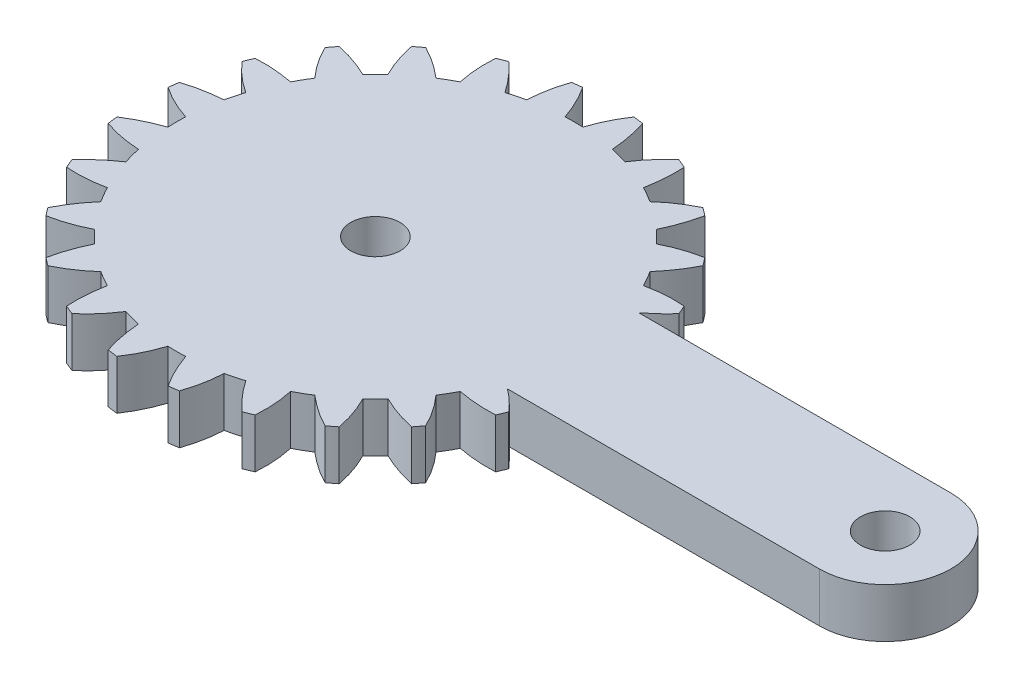
from build123d import *

# Parameters (mm, degrees)
SKETCH2_R           = 1.5
BOSS_EXTRUDE1_DEPTH = 3
SCALE1_SCALE        = 1.8


with BuildPart() as part:
    # Sketch2 → Boss-Extrude1 (new body)
    with BuildSketch(Plane(origin=(0, 0, 0), x_dir=(1, 0, 0), z_dir=(0, 1, 0))):
        with BuildLine():
            Line((31, 4.000000001), (12.012859152, 4.000000001))
            add(Edge.make_bspline(
                [(13.278985865, 5.170206419), (12.8954662, 4.733530556), (12.462190225, 4.344528056), (12.012859152, 4.000000001)],
                knots=[0.154712813, 0.154712813, 0.154712813, 0.154712813, 0.777489596, 0.777489596, 0.777489596, 0.777489596], degree=3))
            ThreePointArc((13.278985865, 5.170206419), (13.165283338, 5.453238911), (13.045548971, 5.733772933))
            add(Edge.make_bspline(
                [(10.729735914, 5.571433139), (11.468148216, 5.731782959), (12.25282672, 5.797378255), (13.045548971, 5.733772933)],
                knots=[0, 0, 0, 0, 0.84522739, 0.84522739, 0.84522739, 0.84522739], degree=3))
            ThreePointArc((10.729735914, 5.571433139), (10.602635836, 5.809665509), (10.470247132, 6.045))
            ThreePointArc((10.470247132, 6.045), (10.332600838, 6.277376835), (10.189798038, 6.506620931))
            add(Edge.make_bspline(
                [(11.488367505, 8.430890348), (11.138958904, 7.723663869), (10.678280228, 7.077546079), (10.189798038, 6.506620931)],
                knots=[0.154712813, 0.154712813, 0.154712813, 0.154712813, 1, 1, 1, 1], degree=3))
            ThreePointArc((11.488367505, 8.430890348), (11.305285099, 8.674850363), (11.117023034, 8.914835886))
            add(Edge.make_bspline(
                [(8.922136024, 8.158651162), (9.593885949, 8.504652361), (10.334849869, 8.771102293), (11.117023034, 8.914835886)],
                knots=[0, 0, 0, 0, 0.84522739, 0.84522739, 0.84522739, 0.84522739], degree=3))
            ThreePointArc((8.922136024, 8.158651162), (8.737707702, 8.35587004), (8.548920985, 8.548920985))
            ThreePointArc((8.548920985, 8.548920985), (8.355821324, 8.737754288), (8.158551674, 8.922226997))
            add(Edge.make_bspline(
                [(8.914835886, 11.117023034), (8.760376776, 10.343461111), (8.482622935, 9.600126837), (8.158551674, 8.922226997)],
                knots=[0.154712813, 0.154712813, 0.154712813, 0.154712813, 1, 1, 1, 1], degree=3))
            ThreePointArc((8.914835886, 11.117023034), (8.674850363, 11.305285099), (8.430890348, 11.488367505))
            add(Edge.make_bspline(
                [(6.506507308, 10.189870591), (7.065816209, 10.697943759), (7.71257008, 11.147090204), (8.430890348, 11.488367505)],
                knots=[0, 0, 0, 0, 0.84522739, 0.84522739, 0.84522739, 0.84522739], degree=3))
            ThreePointArc((6.506507308, 10.189870591), (6.277319227, 10.332635836), (6.045, 10.470247132))
            ThreePointArc((6.045, 10.470247132), (5.809606396, 10.602668227), (5.571313495, 10.729798038))
            add(Edge.make_bspline(
                [(5.733772933, 13.045548971), (5.784789448, 12.258368573), (5.708888907, 11.468474815), (5.571313495, 10.729798038)],
                knots=[0.154712813, 0.154712813, 0.154712813, 0.154712813, 1, 1, 1, 1], degree=3))
            ThreePointArc((5.733772933, 13.045548971), (5.453238911, 13.165283338), (5.170206419, 13.278985865))
            add(Edge.make_bspline(
                [(3.647470872, 11.526667178), (4.056222772, 12.16218797), (4.564691385, 12.76342234), (5.170206419, 13.278985865)],
                knots=[0, 0, 0, 0, 0.84522739, 0.84522739, 0.84522739, 0.84522739], degree=3))
            ThreePointArc((3.647470872, 11.526667178), (3.389141821, 11.605249576), (3.129122255, 11.67804324))
            ThreePointArc((3.129122255, 11.67804324), (2.867476392, 11.745027848), (2.604399509, 11.806151075))
            add(Edge.make_bspline(
                [(2.161962831, 14.085042304), (2.414978279, 13.337888473), (2.546103534, 12.555265188), (2.604399509, 11.806151075)],
                knots=[0.154712813, 0.154712813, 0.154712813, 0.154712813, 1, 1, 1, 1], degree=3))
            ThreePointArc((2.161962831, 14.085042304), (1.859998239, 14.128089275), (1.557181466, 14.164663282))
            add(Edge.make_bspline(
                [(0.539865323, 12.077940447), (0.770204456, 12.797599169), (1.105736515, 13.509948335), (1.557181466, 14.164663282)],
                knots=[0, 0, 0, 0, 0.84522739, 0.84522739, 0.84522739, 0.84522739], degree=3))
            ThreePointArc((0.539865323, 12.077940447), (0.27, 12.086984736), (0, 12.09))
            ThreePointArc((0, 12.09), (-0.270067389, 12.08698323), (-0.54, 12.077934426))
            add(Edge.make_bspline(
                [(-1.557181466, 14.164663282), (-1.119409669, 13.508453317), (-0.790194587, 12.786434986), (-0.54, 12.077934426)],
                knots=[0.154712813, 0.154712813, 0.154712813, 0.154712813, 1, 1, 1, 1], degree=3))
            ThreePointArc((-1.557181466, 14.164663282), (-1.859998239, 14.128089275), (-2.161962831, 14.085042304))
            add(Edge.make_bspline(
                [(-2.604531155, 11.806122033), (-2.568302021, 12.560875133), (-2.42857247, 13.335793678), (-2.161962831, 14.085042304)],
                knots=[0, 0, 0, 0, 0.84522739, 0.84522739, 0.84522739, 0.84522739], degree=3))
            ThreePointArc((-2.604531155, 11.806122033), (-2.867541874, 11.74501186), (-3.129122255, 11.67804324))
            ThreePointArc((-3.129122255, 11.67804324), (-3.389206524, 11.60523068), (-3.647599401, 11.526626506))
            add(Edge.make_bspline(
                [(-5.170206419, 13.278985865), (-4.577511698, 12.75843939), (-4.072642252, 12.146230371), (-3.647599401, 11.526626506)],
                knots=[0.154712813, 0.154712813, 0.154712813, 0.154712813, 1, 1, 1, 1], degree=3))
            ThreePointArc((-5.170206419, 13.278985865), (-5.453238911, 13.165283338), (-5.733772933, 13.045548971))
            add(Edge.make_bspline(
                [(-5.571433139, 10.729735914), (-5.731782959, 11.468148216), (-5.797378255, 12.25282672), (-5.733772933, 13.045548971)],
                knots=[0, 0, 0, 0, 0.84522739, 0.84522739, 0.84522739, 0.84522739], degree=3))
            ThreePointArc((-5.571433139, 10.729735914), (-5.809665509, 10.602635836), (-6.045, 10.470247132))
            ThreePointArc((-6.045, 10.470247132), (-6.277376835, 10.332600838), (-6.506620931, 10.189798038))
            add(Edge.make_bspline(
                [(-8.430890348, 11.488367505), (-7.723663869, 11.138958904), (-7.077546079, 10.678280228), (-6.506620931, 10.189798038)],
                knots=[0.154712813, 0.154712813, 0.154712813, 0.154712813, 1, 1, 1, 1], degree=3))
            ThreePointArc((-8.430890348, 11.488367505), (-8.674850363, 11.305285099), (-8.914835886, 11.117023034))
            add(Edge.make_bspline(
                [(-8.158651162, 8.922136024), (-8.504652361, 9.593885949), (-8.771102293, 10.334849869), (-8.914835886, 11.117023034)],
                knots=[0, 0, 0, 0, 0.84522739, 0.84522739, 0.84522739, 0.84522739], degree=3))
            ThreePointArc((-8.158651162, 8.922136024), (-8.35587004, 8.737707702), (-8.548920985, 8.548920985))
            ThreePointArc((-8.548920985, 8.548920985), (-8.737754288, 8.355821324), (-8.922226997, 8.158551674))
            add(Edge.make_bspline(
                [(-11.117023034, 8.914835886), (-10.343461111, 8.760376776), (-9.600126837, 8.482622935), (-8.922226997, 8.158551674)],
                knots=[0.154712813, 0.154712813, 0.154712813, 0.154712813, 1, 1, 1, 1], degree=3))
            ThreePointArc((-11.117023034, 8.914835886), (-11.305285099, 8.674850363), (-11.488367505, 8.430890348))
            add(Edge.make_bspline(
                [(-10.189870591, 6.506507308), (-10.697943759, 7.065816209), (-11.147090204, 7.71257008), (-11.488367505, 8.430890348)],
                knots=[0, 0, 0, 0, 0.84522739, 0.84522739, 0.84522739, 0.84522739], degree=3))
            ThreePointArc((-10.189870591, 6.506507308), (-10.332635836, 6.277319227), (-10.470247132, 6.045))
            ThreePointArc((-10.470247132, 6.045), (-10.602668227, 5.809606396), (-10.729798038, 5.571313495))
            add(Edge.make_bspline(
                [(-13.045548971, 5.733772933), (-12.258368573, 5.784789448), (-11.468474815, 5.708888907), (-10.729798038, 5.571313495)],
                knots=[0.154712813, 0.154712813, 0.154712813, 0.154712813, 1, 1, 1, 1], degree=3))
            ThreePointArc((-13.045548971, 5.733772933), (-13.165283338, 5.453238911), (-13.278985865, 5.170206419))
            add(Edge.make_bspline(
                [(-11.526667178, 3.647470872), (-12.16218797, 4.056222772), (-12.76342234, 4.564691385), (-13.278985865, 5.170206419)],
                knots=[0, 0, 0, 0, 0.84522739, 0.84522739, 0.84522739, 0.84522739], degree=3))
            ThreePointArc((-11.526667178, 3.647470872), (-11.605249576, 3.389141821), (-11.67804324, 3.129122255))
            ThreePointArc((-11.67804324, 3.129122255), (-11.745027848, 2.867476392), (-11.806151075, 2.604399509))
            add(Edge.make_bspline(
                [(-14.085042304, 2.161962831), (-13.337888473, 2.414978279), (-12.555265188, 2.546103534), (-11.806151075, 2.604399509)],
                knots=[0.154712813, 0.154712813, 0.154712813, 0.154712813, 1, 1, 1, 1], degree=3))
            ThreePointArc((-14.085042304, 2.161962831), (-14.128089275, 1.859998239), (-14.164663282, 1.557181466))
            add(Edge.make_bspline(
                [(-12.077940447, 0.539865323), (-12.797599169, 0.770204456), (-13.509948335, 1.105736515), (-14.164663282, 1.557181466)],
                knots=[0, 0, 0, 0, 0.84522739, 0.84522739, 0.84522739, 0.84522739], degree=3))
            ThreePointArc((-12.077940447, 0.539865323), (-12.086984736, 0.27), (-12.09, 0))
            ThreePointArc((-12.09, 0), (-12.08698323, -0.270067389), (-12.077934426, -0.54))
            add(Edge.make_bspline(
                [(-14.164663282, -1.557181466), (-13.508453317, -1.119409669), (-12.786434986, -0.790194587), (-12.077934426, -0.54)],
                knots=[0.154712813, 0.154712813, 0.154712813, 0.154712813, 1, 1, 1, 1], degree=3))
            ThreePointArc((-14.164663282, -1.557181466), (-14.128089275, -1.859998239), (-14.085042304, -2.161962831))
            add(Edge.make_bspline(
                [(-11.806122033, -2.604531155), (-12.560875133, -2.568302021), (-13.335793678, -2.42857247), (-14.085042304, -2.161962831)],
                knots=[0, 0, 0, 0, 0.84522739, 0.84522739, 0.84522739, 0.84522739], degree=3))
            ThreePointArc((-11.806122033, -2.604531155), (-11.74501186, -2.867541874), (-11.67804324, -3.129122255))
            ThreePointArc((-11.67804324, -3.129122255), (-11.60523068, -3.389206524), (-11.526626506, -3.647599401))
            add(Edge.make_bspline(
                [(-13.278985865, -5.170206419), (-12.75843939, -4.577511698), (-12.146230371, -4.072642252), (-11.526626506, -3.647599401)],
                knots=[0.154712813, 0.154712813, 0.154712813, 0.154712813, 1, 1, 1, 1], degree=3))
            ThreePointArc((-13.278985865, -5.170206419), (-13.165283338, -5.453238911), (-13.045548971, -5.733772933))
            add(Edge.make_bspline(
                [(-10.729735914, -5.571433139), (-11.468148216, -5.731782959), (-12.25282672, -5.797378255), (-13.045548971, -5.733772933)],
                knots=[0, 0, 0, 0, 0.84522739, 0.84522739, 0.84522739, 0.84522739], degree=3))
            ThreePointArc((-10.729735914, -5.571433139), (-10.602635836, -5.809665509), (-10.470247132, -6.045))
            ThreePointArc((-10.470247132, -6.045), (-10.332600838, -6.277376835), (-10.189798038, -6.506620931))
            add(Edge.make_bspline(
                [(-11.488367505, -8.430890348), (-11.138958904, -7.723663869), (-10.678280228, -7.077546079), (-10.189798038, -6.506620931)],
                knots=[0.154712813, 0.154712813, 0.154712813, 0.154712813, 1, 1, 1, 1], degree=3))
            ThreePointArc((-11.488367505, -8.430890348), (-11.305285099, -8.674850363), (-11.117023034, -8.914835886))
            add(Edge.make_bspline(
                [(-8.922136024, -8.158651162), (-9.593885949, -8.504652361), (-10.334849869, -8.771102293), (-11.117023034, -8.914835886)],
                knots=[0, 0, 0, 0, 0.84522739, 0.84522739, 0.84522739, 0.84522739], degree=3))
            ThreePointArc((-8.922136024, -8.158651162), (-8.737707702, -8.35587004), (-8.548920985, -8.548920985))
            ThreePointArc((-8.548920985, -8.548920985), (-8.355821324, -8.737754288), (-8.158551674, -8.922226997))
            add(Edge.make_bspline(
                [(-8.914835886, -11.117023034), (-8.760376776, -10.343461111), (-8.482622935, -9.600126837), (-8.158551674, -8.922226997)],
                knots=[0.154712813, 0.154712813, 0.154712813, 0.154712813, 1, 1, 1, 1], degree=3))
            ThreePointArc((-8.914835886, -11.117023034), (-8.674850363, -11.305285099), (-8.430890348, -11.488367505))
            add(Edge.make_bspline(
                [(-6.506507308, -10.189870591), (-7.065816209, -10.697943759), (-7.71257008, -11.147090204), (-8.430890348, -11.488367505)],
                knots=[0, 0, 0, 0, 0.84522739, 0.84522739, 0.84522739, 0.84522739], degree=3))
            ThreePointArc((-6.506507308, -10.189870591), (-6.277319227, -10.332635836), (-6.045, -10.470247132))
            ThreePointArc((-6.045, -10.470247132), (-5.809606396, -10.602668227), (-5.571313495, -10.729798038))
            add(Edge.make_bspline(
                [(-5.733772933, -13.045548971), (-5.784789448, -12.258368573), (-5.708888907, -11.468474815), (-5.571313495, -10.729798038)],
                knots=[0.154712813, 0.154712813, 0.154712813, 0.154712813, 1, 1, 1, 1], degree=3))
            ThreePointArc((-5.733772933, -13.045548971), (-5.453238911, -13.165283338), (-5.170206419, -13.278985865))
            add(Edge.make_bspline(
                [(-3.647470872, -11.526667178), (-4.056222772, -12.16218797), (-4.564691385, -12.76342234), (-5.170206419, -13.278985865)],
                knots=[0, 0, 0, 0, 0.84522739, 0.84522739, 0.84522739, 0.84522739], degree=3))
            ThreePointArc((-3.647470872, -11.526667178), (-3.389141821, -11.605249576), (-3.129122255, -11.67804324))
            ThreePointArc((-3.129122255, -11.67804324), (-2.867476392, -11.745027848), (-2.604399509, -11.806151075))
            add(Edge.make_bspline(
                [(-2.161962831, -14.085042304), (-2.414978279, -13.337888473), (-2.546103534, -12.555265188), (-2.604399509, -11.806151075)],
                knots=[0.154712813, 0.154712813, 0.154712813, 0.154712813, 1, 1, 1, 1], degree=3))
            ThreePointArc((-2.161962831, -14.085042304), (-1.859998239, -14.128089275), (-1.557181466, -14.164663282))
            add(Edge.make_bspline(
                [(-0.539865323, -12.077940447), (-0.770204456, -12.797599169), (-1.105736515, -13.509948335), (-1.557181466, -14.164663282)],
                knots=[0, 0, 0, 0, 0.84522739, 0.84522739, 0.84522739, 0.84522739], degree=3))
            ThreePointArc((-0.539865323, -12.077940447), (-0.27, -12.086984736), (0, -12.09))
            ThreePointArc((0, -12.09), (0.270067389, -12.08698323), (0.54, -12.077934426))
            add(Edge.make_bspline(
                [(1.557181466, -14.164663282), (1.119409669, -13.508453317), (0.790194587, -12.786434986), (0.54, -12.077934426)],
                knots=[0.154712813, 0.154712813, 0.154712813, 0.154712813, 1, 1, 1, 1], degree=3))
            ThreePointArc((1.557181466, -14.164663282), (1.859998239, -14.128089275), (2.161962831, -14.085042304))
            add(Edge.make_bspline(
                [(2.604531155, -11.806122033), (2.568302021, -12.560875133), (2.42857247, -13.335793678), (2.161962831, -14.085042304)],
                knots=[0, 0, 0, 0, 0.84522739, 0.84522739, 0.84522739, 0.84522739], degree=3))
            ThreePointArc((2.604531155, -11.806122033), (2.867541874, -11.74501186), (3.129122255, -11.67804324))
            ThreePointArc((3.129122255, -11.67804324), (3.389206524, -11.60523068), (3.647599401, -11.526626506))
            add(Edge.make_bspline(
                [(5.170206419, -13.278985865), (4.577511698, -12.75843939), (4.072642252, -12.146230371), (3.647599401, -11.526626506)],
                knots=[0.154712813, 0.154712813, 0.154712813, 0.154712813, 1, 1, 1, 1], degree=3))
            ThreePointArc((5.170206419, -13.278985865), (5.453238911, -13.165283338), (5.733772933, -13.045548971))
            add(Edge.make_bspline(
                [(5.571433139, -10.729735914), (5.731782959, -11.468148216), (5.797378255, -12.25282672), (5.733772933, -13.045548971)],
                knots=[0, 0, 0, 0, 0.84522739, 0.84522739, 0.84522739, 0.84522739], degree=3))
            ThreePointArc((5.571433139, -10.729735914), (5.809665509, -10.602635836), (6.045, -10.470247132))
            ThreePointArc((6.045, -10.470247132), (6.277376835, -10.332600838), (6.506620931, -10.189798038))
            add(Edge.make_bspline(
                [(8.430890348, -11.488367505), (7.723663869, -11.138958904), (7.077546079, -10.678280228), (6.506620931, -10.189798038)],
                knots=[0.154712813, 0.154712813, 0.154712813, 0.154712813, 1, 1, 1, 1], degree=3))
            ThreePointArc((8.430890348, -11.488367505), (8.674850363, -11.305285099), (8.914835886, -11.117023034))
            add(Edge.make_bspline(
                [(8.158651162, -8.922136024), (8.504652361, -9.593885949), (8.771102293, -10.334849869), (8.914835886, -11.117023034)],
                knots=[0, 0, 0, 0, 0.84522739, 0.84522739, 0.84522739, 0.84522739], degree=3))
            ThreePointArc((8.158651162, -8.922136024), (8.35587004, -8.737707702), (8.548920985, -8.548920985))
            ThreePointArc((8.548920985, -8.548920985), (8.737754288, -8.355821324), (8.922226997, -8.158551674))
            add(Edge.make_bspline(
                [(11.117023034, -8.914835886), (10.343461111, -8.760376776), (9.600126837, -8.482622935), (8.922226997, -8.158551674)],
                knots=[0.154712813, 0.154712813, 0.154712813, 0.154712813, 1, 1, 1, 1], degree=3))
            ThreePointArc((11.117023034, -8.914835886), (11.305285099, -8.674850363), (11.488367505, -8.430890348))
            add(Edge.make_bspline(
                [(10.189870591, -6.506507308), (10.697943759, -7.065816209), (11.147090204, -7.71257008), (11.488367505, -8.430890348)],
                knots=[0, 0, 0, 0, 0.84522739, 0.84522739, 0.84522739, 0.84522739], degree=3))
            ThreePointArc((10.189870591, -6.506507308), (10.332635836, -6.277319227), (10.470247132, -6.045))
            ThreePointArc((10.470247132, -6.045), (10.602668227, -5.809606396), (10.729798038, -5.571313495))
            add(Edge.make_bspline(
                [(13.045548971, -5.733772933), (12.258368573, -5.784789448), (11.468474815, -5.708888907), (10.729798038, -5.571313495)],
                knots=[0.154712813, 0.154712813, 0.154712813, 0.154712813, 1, 1, 1, 1], degree=3))
            ThreePointArc((13.045548971, -5.733772933), (13.165283338, -5.453238911), (13.278985865, -5.170206419))
            add(Edge.make_bspline(
                [(12.032510858, -3.999999999), (12.480346232, -4.337627374), (12.902507267, -4.728042767), (13.278985865, -5.170206419)],
                knots=[0.228019214, 0.228019214, 0.228019214, 0.228019214, 0.84522739, 0.84522739, 0.84522739, 0.84522739], degree=3))
            Line((12.032510858, -3.999999999), (31, -3.999999999))
            ThreePointArc((31, -3.999999999), (35, 1e-09), (31, 4.000000001))
        make_face()
        with Locations((31, 1e-09)):
            Circle(SKETCH2_R, mode=Mode.SUBTRACT)
        Circle(SKETCH2_R, mode=Mode.SUBTRACT)
    extrude(amount=BOSS_EXTRUDE1_DEPTH)


with BuildPart() as part_1:
    # Scale1: scaled about (5.488849997, 1.5, 2.1149e-05)
    add(part.part.scale(SCALE1_SCALE).moved(Location((-4.391079998, -1.2, -1.6919e-05))))


solid = part_1.part
